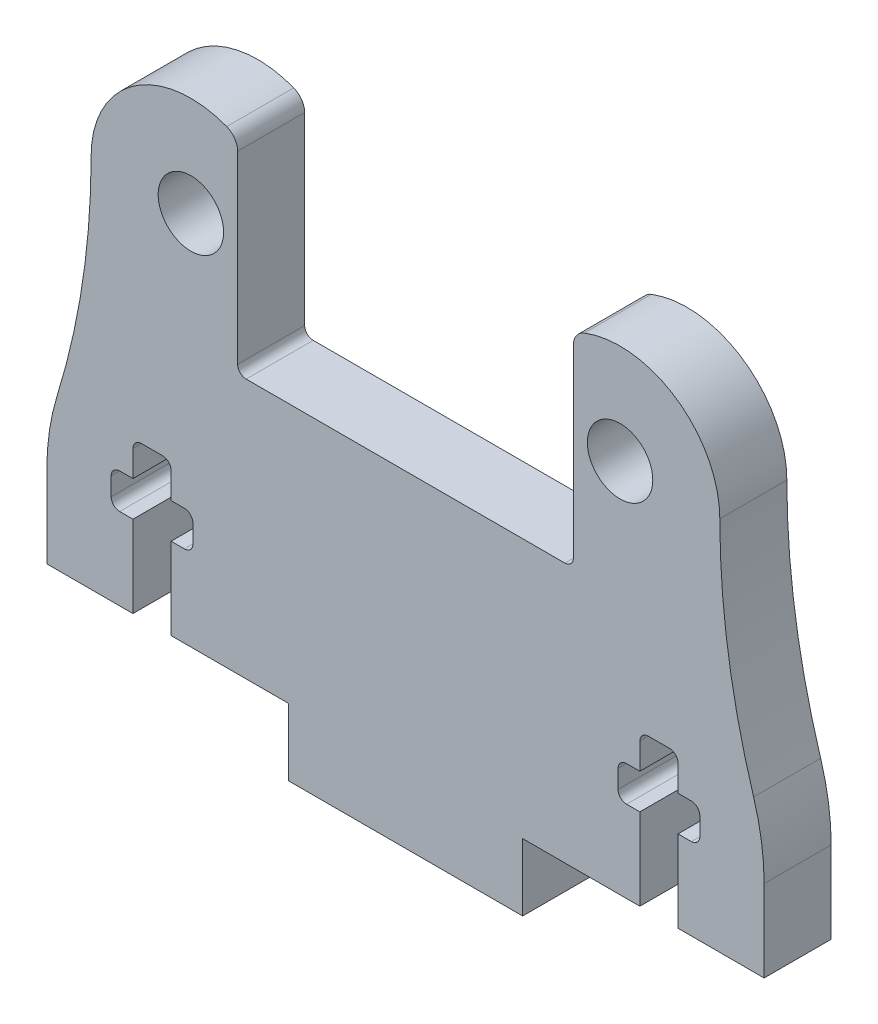
from build123d import *

# Parameters (mm, degrees)
CROQUIS1_R              = 1.524
SALIENTE_EXTRUIR1_DEPTH = 3.1242


with BuildPart() as part:
    # Croquis1 → Saliente-Extruir1 (new body)
    with BuildSketch(Plane.XY):
        with BuildLine():
            ThreePointArc((8.332137397, 4.338663109), (7.962691234, 4.047198075), (7.8232, 3.597771185))
            Line((7.8232, 3.597771185), (7.8232, -5.000625))
            ThreePointArc((7.8232, -5.000625), (7.706958004, -5.281258004), (7.426325, -5.3975))
            Line((7.426325, -5.3975), (-7.426325, -5.3975))
            ThreePointArc((-7.426325, -5.3975), (-7.706958004, -5.281258004), (-7.8232, -5.000625))
            Line((-7.8232, -5.000625), (-7.8232, 3.597771185))
            ThreePointArc((-7.8232, 3.597771185), (-7.962691234, 4.047198075), (-8.332137397, 4.338663109))
            ThreePointArc((-8.332137397, 4.338663109), (-12.631843868, 3.831339334), (-14.6482, 0))
            ThreePointArc((-14.6482, 0), (-15.044061243, -5.278443796), (-16.222788897, -10.4388))
            ThreePointArc((-16.222788897, -10.4388), (-16.58990766, -12.046010608), (-16.7132, -13.69))
            Line((-16.7132, -13.69), (-16.7132, -17.5))
            Line((-16.7132, -17.5), (-12.7, -17.5))
            Line((-12.7, -17.5), (-12.7, -13.69))
            Line((-12.7, -13.69), (-13.319125, -13.69))
            ThreePointArc((-13.319125, -13.69), (-13.599758004, -13.573758004), (-13.716, -13.293125))
            Line((-13.716, -13.293125), (-13.716, -12.448575))
            ThreePointArc((-13.716, -12.448575), (-13.599758004, -12.167941996), (-13.319125, -12.0517))
            Line((-13.319125, -12.0517), (-12.7, -12.0517))
            Line((-12.7, -12.0517), (-12.7, -10.835675))
            ThreePointArc((-12.7, -10.835675), (-12.583758004, -10.555041996), (-12.303125, -10.4388))
            Line((-12.303125, -10.4388), (-11.318875, -10.4388))
            ThreePointArc((-11.318875, -10.4388), (-11.038241996, -10.555041996), (-10.922, -10.835675))
            Line((-10.922, -10.835675), (-10.922, -12.0517))
            Line((-10.922, -12.0517), (-10.302875, -12.0517))
            ThreePointArc((-10.302875, -12.0517), (-10.022241996, -12.167941996), (-9.906, -12.448575))
            Line((-9.906, -12.448575), (-9.906, -13.293125))
            ThreePointArc((-9.906, -13.293125), (-10.022241996, -13.573758004), (-10.302875, -13.69))
            Line((-10.302875, -13.69), (-10.922, -13.69))
            Line((-10.922, -13.69), (-10.922, -17.5))
            Line((-10.922, -17.5), (-5.461, -17.5))
            Line((-5.461, -17.5), (-5.461, -20.6242))
            Line((-5.461, -20.6242), (5.461, -20.6242))
            Line((5.461, -20.6242), (5.461, -17.5))
            Line((5.461, -17.5), (10.922, -17.5))
            Line((10.922, -17.5), (10.922, -13.69))
            Line((10.922, -13.69), (10.302875, -13.69))
            ThreePointArc((10.302875, -13.69), (10.022241996, -13.573758004), (9.906, -13.293125))
            Line((9.906, -13.293125), (9.906, -12.448575))
            ThreePointArc((9.906, -12.448575), (10.022241996, -12.167941996), (10.302875, -12.0517))
            Line((10.302875, -12.0517), (10.922, -12.0517))
            Line((10.922, -12.0517), (10.922, -10.835675))
            ThreePointArc((10.922, -10.835675), (11.038241996, -10.555041996), (11.318875, -10.4388))
            Line((11.318875, -10.4388), (12.303125, -10.4388))
            ThreePointArc((12.303125, -10.4388), (12.583758004, -10.555041996), (12.7, -10.835675))
            Line((12.7, -10.835675), (12.7, -12.0517))
            Line((12.7, -12.0517), (13.319125, -12.0517))
            ThreePointArc((13.319125, -12.0517), (13.599758004, -12.167941996), (13.716, -12.448575))
            Line((13.716, -12.448575), (13.716, -13.293125))
            ThreePointArc((13.716, -13.293125), (13.599758004, -13.573758004), (13.319125, -13.69))
            Line((13.319125, -13.69), (12.7, -13.69))
            Line((12.7, -13.69), (12.7, -17.5))
            Line((12.7, -17.5), (16.7132, -17.5))
            Line((16.7132, -17.5), (16.7132, -13.69))
            ThreePointArc((16.7132, -13.69), (16.58990766, -12.046010608), (16.222788897, -10.4388))
            ThreePointArc((16.222788897, -10.4388), (15.044061243, -5.278443796), (14.6482, 0))
            ThreePointArc((14.6482, 0), (12.631843868, 3.831339334), (8.332137397, 4.338663109))
        make_face()
        with Locations((10, 0)):
            Circle(CROQUIS1_R, mode=Mode.SUBTRACT)
        with Locations((-10, 0)):
            Circle(CROQUIS1_R, mode=Mode.SUBTRACT)
    extrude(amount=SALIENTE_EXTRUIR1_DEPTH)


solid = part.part
